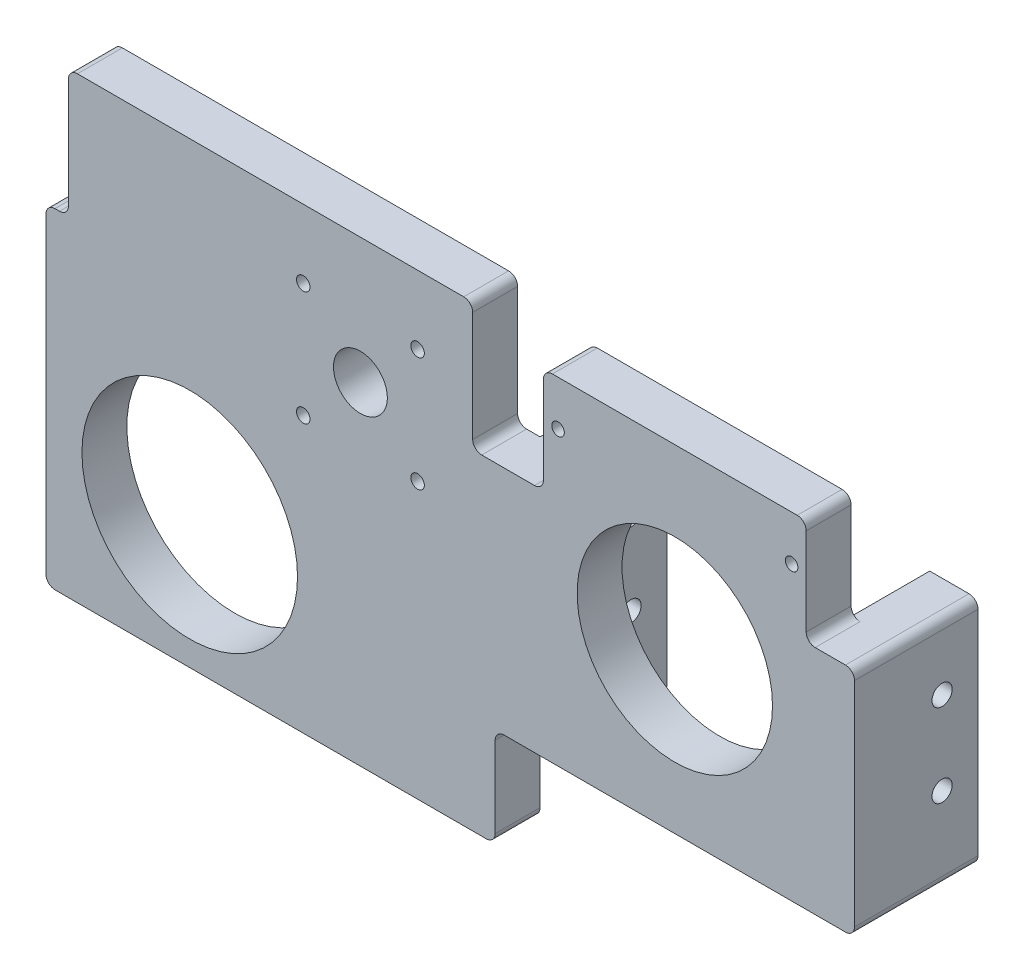
from build123d import *

# Parameters (mm, degrees)
BOSS_EXTRUDE1_DEPTH = 80
SKETCH2_R           = 21.75
CUT_EXTRUDE1_DEPTH  = 10
SKETCH3_R           = 1.4
CUT_EXTRUDE2_DEPTH  = 4
CUT_EXTRUDE3_DEPTH  = 6
SKETCH5_R           = 2.25
CUT_EXTRUDE4_DEPTH  = 81
SKETCH6_W           = 10.75
SKETCH6_H           = 28.5
CUT_EXTRUDE5_DEPTH  = 28.5
BOSS_EXTRUDE2_DEPTH = 100
SKETCH8_W           = 5
SKETCH8_H           = 28.5
CUT_EXTRUDE6_DEPTH  = 80
SKETCH9_R           = 24
CUT_EXTRUDE7_DEPTH  = 80
SKETCH12_R          = 6
CUT_EXTRUDE9_DEPTH  = 28
SKETCH13_W          = 58.5
SKETCH13_H          = 5
CUT_EXTRUDE10_DEPTH = 28.5
FILLET2_R           = 2
SKETCH15_R          = 1.5
CUT_EXTRUDE11_DEPTH = 28.5


with BuildPart() as part:
    # Sketch1 → Boss-Extrude1 (new body)
    with BuildSketch(Plane(origin=(0, 0, 0), x_dir=(1, 0, 0), z_dir=(0, 1, 0))):
        Polygon((-40, -13.75), (40, -13.75), (40, 13.75), (29.25, 13.75), (29.25, -3.75), (-29.25, -3.75), (-29.25, 13.75), (-40, 13.75), align=None)
    extrude(amount=BOSS_EXTRUDE1_DEPTH)

    # Sketch2 → Cut-Extrude1 (cut)
    with BuildSketch(Plane.XY.offset(13.75)):
        with Locations((0, 35.5)):
            Circle(SKETCH2_R)
    extrude(amount=-CUT_EXTRUDE1_DEPTH, mode=Mode.SUBTRACT)

    # Sketch3 → Cut-Extrude2 (cut)
    with BuildSketch(Plane.XY.offset(13.75)):
        with Locations((26, 65)):
            Circle(SKETCH3_R)
        with Locations((-26, 65)):
            Circle(SKETCH3_R)
    extrude(amount=-CUT_EXTRUDE2_DEPTH, mode=Mode.SUBTRACT)

    # Sketch4 → Cut-Extrude3 (cut)
    with BuildSketch(Plane(origin=(0, 0, 3.75), x_dir=(-1, 0, 0), z_dir=(0, 0, -1))):
        Polygon((-27.21, 62.904218523), (-28.42, 65), (-27.21, 67.095781477), (-24.79, 67.095781477), (-23.58, 65), (-24.79, 62.904218523), align=None)
        Polygon((28.42, 65), (27.21, 67.095781477), (24.79, 67.095781477), (23.58, 65), (24.79, 62.904218523), (27.21, 62.904218523), align=None)
    extrude(amount=-CUT_EXTRUDE3_DEPTH, mode=Mode.SUBTRACT)

    # Sketch5 → Cut-Extrude4 (cut, through all)
    with BuildSketch(Plane(origin=(40, 0, 0), x_dir=(0, 0, -1), z_dir=(1, 0, 0))):
        with Locations((5.75, 18.5)):
            Circle(SKETCH5_R)
        with Locations((5.75, 37)):
            Circle(SKETCH5_R)
    extrude(amount=-CUT_EXTRUDE4_DEPTH, mode=Mode.SUBTRACT)

    # Sketch6 → Cut-Extrude5 (cut, through all)
    with BuildSketch(Plane.XY.offset(13.75)):
        with Locations((-34.625, 65.75)):
            Rectangle(SKETCH6_W, SKETCH6_H)
        with Locations((34.625, 65.75)):
            Rectangle(SKETCH6_W, SKETCH6_H)
    extrude(amount=-CUT_EXTRUDE5_DEPTH, mode=Mode.SUBTRACT)

    # Sketch7 → Boss-Extrude2 (add)
    with BuildSketch(Plane.ZY.offset(40)):
        Polygon((3.75, 0), (3.75, -22), (13.75, -22), (13.75, 0), (13.75, 80), (3.75, 80), align=None)
    extrude(amount=BOSS_EXTRUDE2_DEPTH)

    # Sketch8 → Cut-Extrude6 (cut)
    with BuildSketch(Plane.XY.offset(13.75)):
        with Locations((-42.5, 65.75)):
            Rectangle(SKETCH8_W, SKETCH8_H)
        with Locations((-137.5, 65.75)):
            Rectangle(SKETCH8_W, SKETCH8_H)
    extrude(amount=-CUT_EXTRUDE6_DEPTH, mode=Mode.SUBTRACT)

    # Sketch9 → Cut-Extrude7 (cut)
    with BuildSketch(Plane.XY.offset(13.75)):
        with Locations((-108, 7.5)):
            Circle(SKETCH9_R)
    extrude(amount=-CUT_EXTRUDE7_DEPTH, mode=Mode.SUBTRACT)

    # Sketch12 → Cut-Extrude9 (cut)
    with BuildSketch(Plane.XY.offset(13.75)):
        with Locations((-70, 52)):
            Circle(SKETCH12_R)
    extrude(amount=-CUT_EXTRUDE9_DEPTH, mode=Mode.SUBTRACT)

    # Sketch13 → Cut-Extrude10 (cut, through all)
    with BuildSketch(Plane.XY.offset(13.75)):
        with Locations((0, 77.5)):
            Rectangle(SKETCH13_W, SKETCH13_H)
    extrude(amount=-CUT_EXTRUDE10_DEPTH, mode=Mode.SUBTRACT)

    # Fillet2
    fillet2_edges = [part.edges().sort_by_distance(p)[0] for p in [
        (-29.25, 51.5, 8.75),
        (29.25, 51.5, 8.75),
        (40, 51.5, 0),
        (-40, 0, 8.75),
        (-40, -22, 8.75),
        (-140, -22, 8.75),
        (-140, 51.5, 8.75),
        (-45, 51.5, 8.75),
        (-45, 80, 8.75),
        (-135, 80, 8.75),
        (-135, 51.5, 8.75),
        (-29.25, 75, 8.75),
        (29.25, 75, 8.75),
        (40, 0, 0),
    ]]
    fillet(fillet2_edges, radius=FILLET2_R)

    # Sketch15 → Cut-Extrude11 (cut, through all)
    with BuildSketch(Plane.XY.offset(13.75)):
        with Locations((-57.272077939, 64.727922061)):
            Circle(SKETCH15_R)
        with Locations((-57.272077939, 39.272077939)):
            Circle(SKETCH15_R)
        with Locations((-82.727922061, 39.272077939)):
            Circle(SKETCH15_R)
        with Locations((-82.727922061, 64.727922061)):
            Circle(SKETCH15_R)
    extrude(amount=-CUT_EXTRUDE11_DEPTH, mode=Mode.SUBTRACT)


solid = part.part
